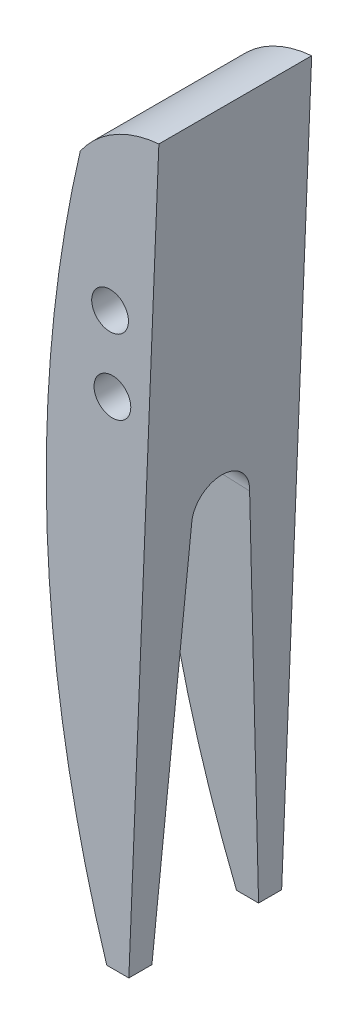
from build123d import *

# Parameters (mm, degrees)
SKETCH1_R           = 1.2065
BOSS_EXTRUDE1_DEPTH = 10.033
CUT_EXTRUDE1_DEPTH  = 10.033
CUT_EXTRUDE2_DEPTH  = 10.033


with BuildPart() as part:
    # Sketch1 → Boss-Extrude1 (new body)
    with BuildSketch(Plane.XY):
        with BuildLine():
            Line((74.127846298, 88.795942837), (72.00043944, 36.574422097))
            ThreePointArc((72.00043944, 36.574422097), (66.89810991, 60.973237803), (68.966334727, 85.813898433))
            ThreePointArc((68.966334727, 85.813898433), (71.21567331, 87.878558548), (74.127846298, 88.795942837))
        make_face()
        with Locations((70.925382829, 77.722422097)):
            Circle(SKETCH1_R, mode=Mode.SUBTRACT)
        with Locations((71.077782829, 72.896422097)):
            Circle(SKETCH1_R, mode=Mode.SUBTRACT)
    extrude(amount=BOSS_EXTRUDE1_DEPTH)

    # Sketch2 → Cut-Extrude1 (cut)
    with BuildSketch(Plane(origin=(70.393641123, -2.867704976, 0), x_dir=(0, 0, -1), z_dir=(0.999171234, -0.040704363, 0))):
        with BuildLine():
            Line((-1.27, 39.474842481), (-8.763, 39.474842481))
            Line((-8.763, 39.474842481), (-6.9215, 68.049842481))
            ThreePointArc((-6.9215, 68.049842481), (-5.0165, 69.954842481), (-3.1115, 68.049842481))
            Line((-3.1115, 68.049842481), (-1.27, 39.474842481))
        make_face()
    extrude(amount=-CUT_EXTRUDE1_DEPTH, mode=Mode.SUBTRACT)

    # Sketch3 → Cut-Extrude2 (cut)
    with BuildSketch(Plane.XY.offset(10.033)):
        with BuildLine():
            Line((70.704380761, 40.389805653), (72.155871014, 40.389805653))
            Line((72.155871014, 40.389805653), (72.00043944, 36.574422097))
            ThreePointArc((72.00043944, 36.574422097), (71.330186821, 38.474564785), (70.704380761, 40.389805653))
        make_face()
    extrude(amount=-CUT_EXTRUDE2_DEPTH, mode=Mode.SUBTRACT)


solid = part.part
